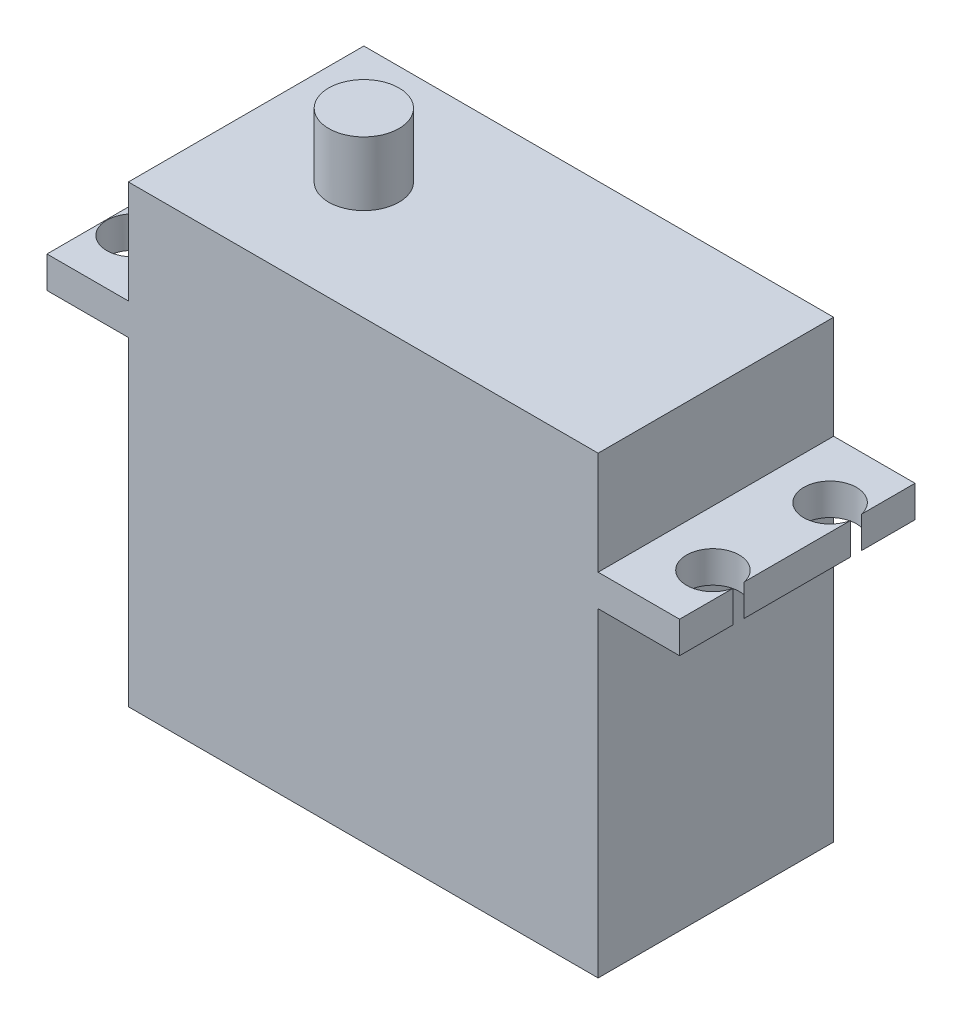
from build123d import *

# Parameters (mm, degrees)
SKETCH_1_W          = 40.1
SKETCH_1_H          = 20.1
EXTRUDE_2_DEPTH     = 38.8
SKETCH_2_W          = 54
SKETCH_2_H          = 20.1
EXTRUDE_3_DEPTH     = 2.7
SKETCH_4_R          = 3
EXTRUDE_4_DEPTH     = 5.45
SKETCH_5_R          = 2.25
CUT_EXTRUDE_1_DEPTH = 31
SKETCH_6_W          = 8
SKETCH_6_H          = 4
EXTRUDE_5_DEPTH     = 3


with BuildPart() as part:
    # ｽｹｯﾁ1 → ﾎﾞｽ - 押し出し2 (new body)
    with BuildSketch(Plane(origin=(0, 0, 0), x_dir=(1, 0, 0), z_dir=(0, 1, 0))):
        Rectangle(SKETCH_1_W, SKETCH_1_H)
    extrude(amount=EXTRUDE_2_DEPTH)

    # ｽｹｯﾁ2 → ﾎﾞｽ - 押し出し3 (add)
    with BuildSketch(Plane(origin=(0, 30, 0), x_dir=(-1, 0, 0), z_dir=(0, -1, 0))):
        Rectangle(SKETCH_2_W, SKETCH_2_H)
    extrude(amount=EXTRUDE_3_DEPTH)

    # ｽｹｯﾁ4 → ﾎﾞｽ - 押し出し4 (add)
    with BuildSketch(Plane(origin=(0, 38.8, 0), x_dir=(1, 0, 0), z_dir=(0, 1, 0))):
        with Locations((-10, 0)):
            Circle(SKETCH_4_R)
    extrude(amount=EXTRUDE_4_DEPTH)

    # ｽｹｯﾁ5 → ｶｯﾄ - 押し出し1 (cut, through all)
    with BuildSketch(Plane(origin=(0, 30, 0), x_dir=(1, 0, 0), z_dir=(0, 1, 0))):
        with Locations((24.8, 5)):
            Circle(SKETCH_5_R)
        with Locations((24.8, -5)):
            Circle(SKETCH_5_R)
        with Locations((-24.7, 5)):
            Circle(SKETCH_5_R)
        with Locations((-24.7, -5)):
            Circle(SKETCH_5_R)
    extrude(amount=-CUT_EXTRUDE_1_DEPTH, mode=Mode.SUBTRACT)

    # ｽｹｯﾁ6 → ﾎﾞｽ - 押し出し5 (add)
    with BuildSketch(Plane.ZY.offset(20.05)):
        with Locations((0, 9)):
            Rectangle(SKETCH_6_W, SKETCH_6_H)
    extrude(amount=EXTRUDE_5_DEPTH)


solid = part.part
